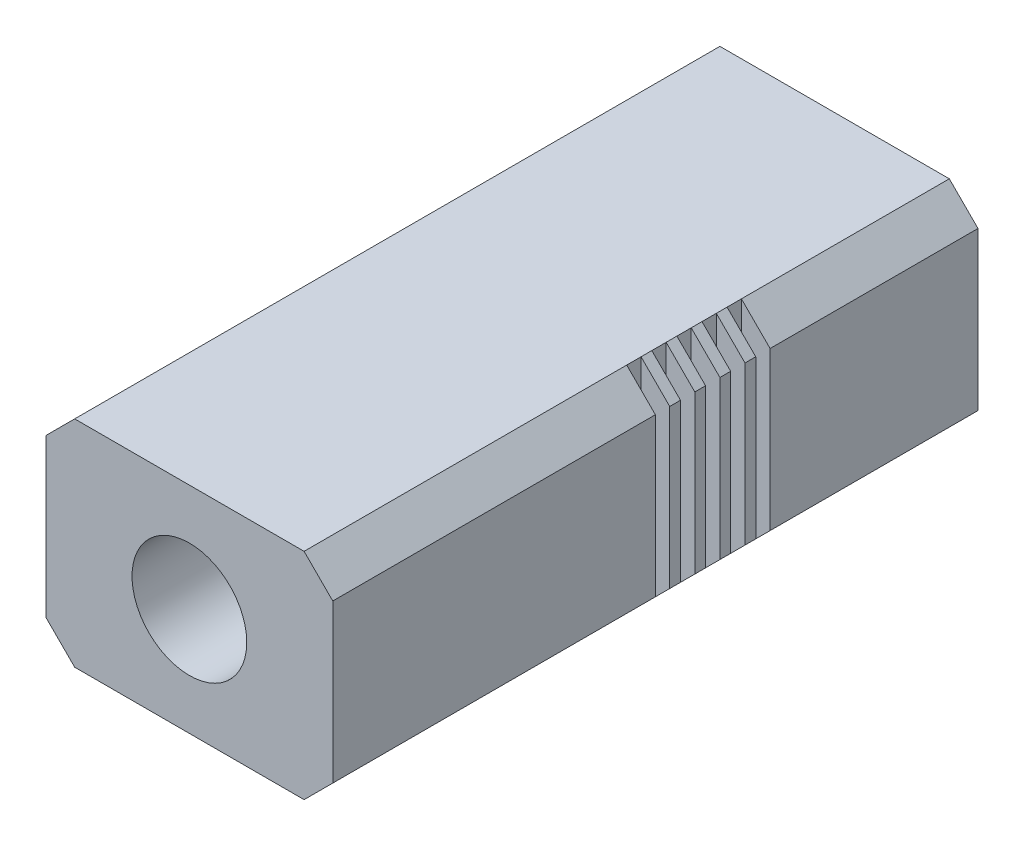
from build123d import *

# Parameters (mm, degrees)
SKETCH1_W           = 20
SKETCH1_H           = 15
BOSS_EXTRUDE1_DEPTH = 45
SKETCH2_R           = 4
CUT_EXTRUDE1_DEPTH  = 46
CHAMFER1_SIZE       = 2
SKETCH4_W           = 2
SKETCH4_H           = 1
CUT_EXTRUDE2_DEPTH  = 16
SKETCH5_W           = 4
SKETCH5_H           = 8
SKETCH5_R           = 1.25
CUT_EXTRUDE3_DEPTH  = 1


with BuildPart() as part:
    # Sketch1 → Boss-Extrude1 (new body)
    with BuildSketch(Plane.XY):
        Rectangle(SKETCH1_W, SKETCH1_H)
    extrude(amount=BOSS_EXTRUDE1_DEPTH)

    # Sketch2 → Cut-Extrude1 (cut, through all)
    with BuildSketch(Plane.XY.offset(45)):
        Circle(SKETCH2_R)
    extrude(amount=-CUT_EXTRUDE1_DEPTH, mode=Mode.SUBTRACT)

    # Chamfer1
    chamfer1_edges = [part.edges().sort_by_distance(p)[0] for p in [
        (10, 7.5, 22.5),
        (10, -7.5, 22.5),
        (-10, -7.5, 22.5),
        (-10, 7.5, 22.5),
    ]]
    chamfer(chamfer1_edges, length=CHAMFER1_SIZE)

    # Sketch4 → Cut-Extrude2 (cut, through all)
    with BuildSketch(Plane.XZ.offset(7.5)):
        with Locations((-9, 15)):
            Rectangle(SKETCH4_W, SKETCH4_H)
        with Locations((-9, 16.75)):
            Rectangle(SKETCH4_W, SKETCH4_H)
        with Locations((-9, 18.5)):
            Rectangle(SKETCH4_W, SKETCH4_H)
        with Locations((-9, 20.25)):
            Rectangle(SKETCH4_W, SKETCH4_H)
        with Locations((-9, 22)):
            Rectangle(SKETCH4_W, SKETCH4_H)
        with Locations((9, 22)):
            Rectangle(SKETCH4_W, SKETCH4_H)
        with Locations((9, 20.25)):
            Rectangle(SKETCH4_W, SKETCH4_H)
        with Locations((9, 18.5)):
            Rectangle(SKETCH4_W, SKETCH4_H)
        with Locations((9, 16.75)):
            Rectangle(SKETCH4_W, SKETCH4_H)
        with Locations((9, 15)):
            Rectangle(SKETCH4_W, SKETCH4_H)
    extrude(amount=-CUT_EXTRUDE2_DEPTH, mode=Mode.SUBTRACT)

    # Sketch5 → Cut-Extrude3 (cut)
    with BuildSketch(Plane.XZ.offset(7.5)):
        with Locations((0, 12)):
            Rectangle(SKETCH5_W, SKETCH5_H)
        with Locations((0, 11)):
            Circle(SKETCH5_R, mode=Mode.SUBTRACT)
    extrude(amount=-CUT_EXTRUDE3_DEPTH, mode=Mode.SUBTRACT)


solid = part.part
